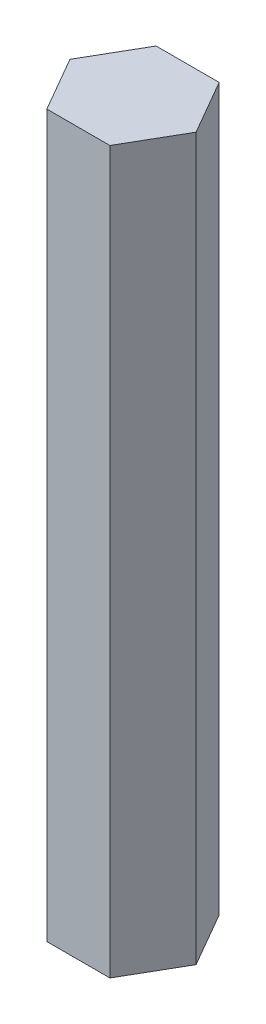
from build123d import *

# Parameters (mm, degrees)
BOSS_EXTRUDE1_DEPTH = 83.82


with BuildPart() as part:
    # Sketch1 → Boss-Extrude1 (new body)
    with BuildSketch(Plane(origin=(0, 0, 0), x_dir=(1, 0, 0), z_dir=(0, 1, 0))):
        Polygon((3.666174209, 6.35), (-3.666174209, 6.35), (-7.332348419, 0), (-3.666174209, -6.35), (3.666174209, -6.35), (7.332348419, 0), align=None)
    extrude(amount=BOSS_EXTRUDE1_DEPTH)


solid = part.part
